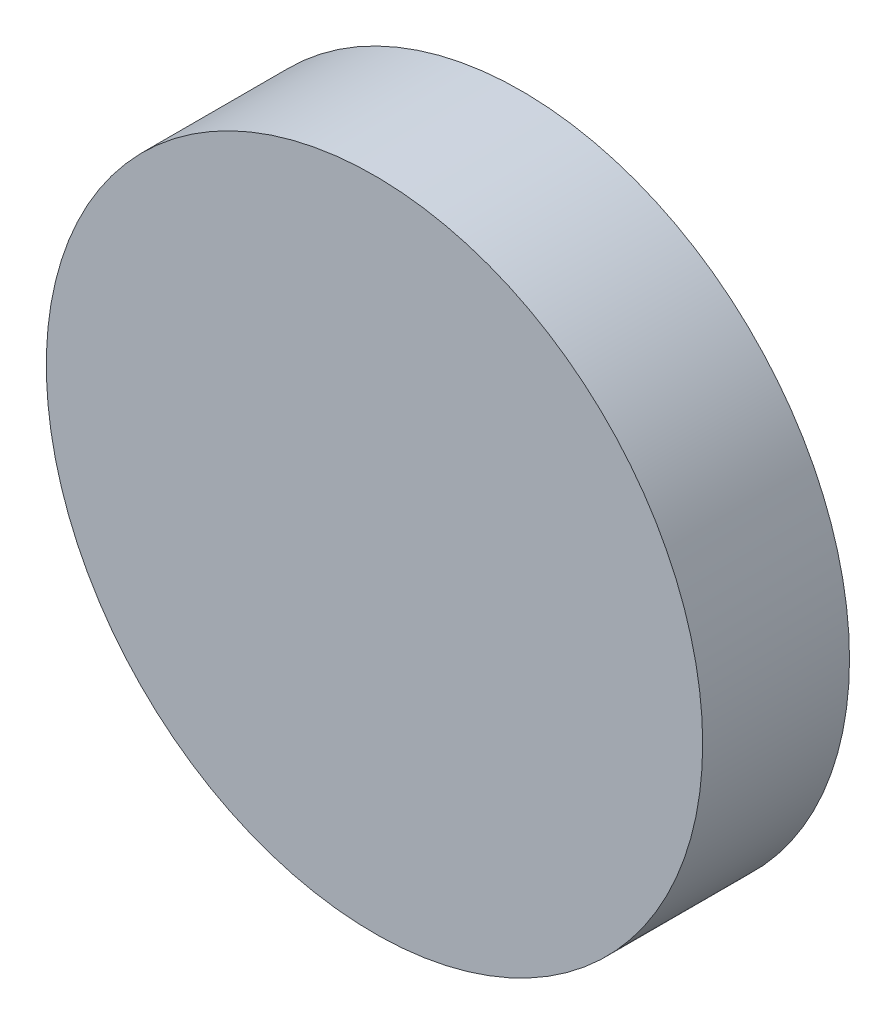
from build123d import *

# Parameters (mm, degrees)
IZIM3_R                     = 380
Y_KSEKLIK_EKSTR_ZYON3_DEPTH = 170
SCALE1_SCALE                = 0.5


with BuildPart() as part:
    # Çizim3 → Yükseklik-Ekstrüzyon3 (new body)
    with BuildSketch(Plane.XY):
        Circle(IZIM3_R)
    extrude(amount=Y_KSEKLIK_EKSTR_ZYON3_DEPTH)


with BuildPart() as part_1:
    # Scale1: scaled about (0, 0, 85)
    add(part.part.scale(SCALE1_SCALE).moved(Location((0, 0, 42.5))))


solid = part_1.part
